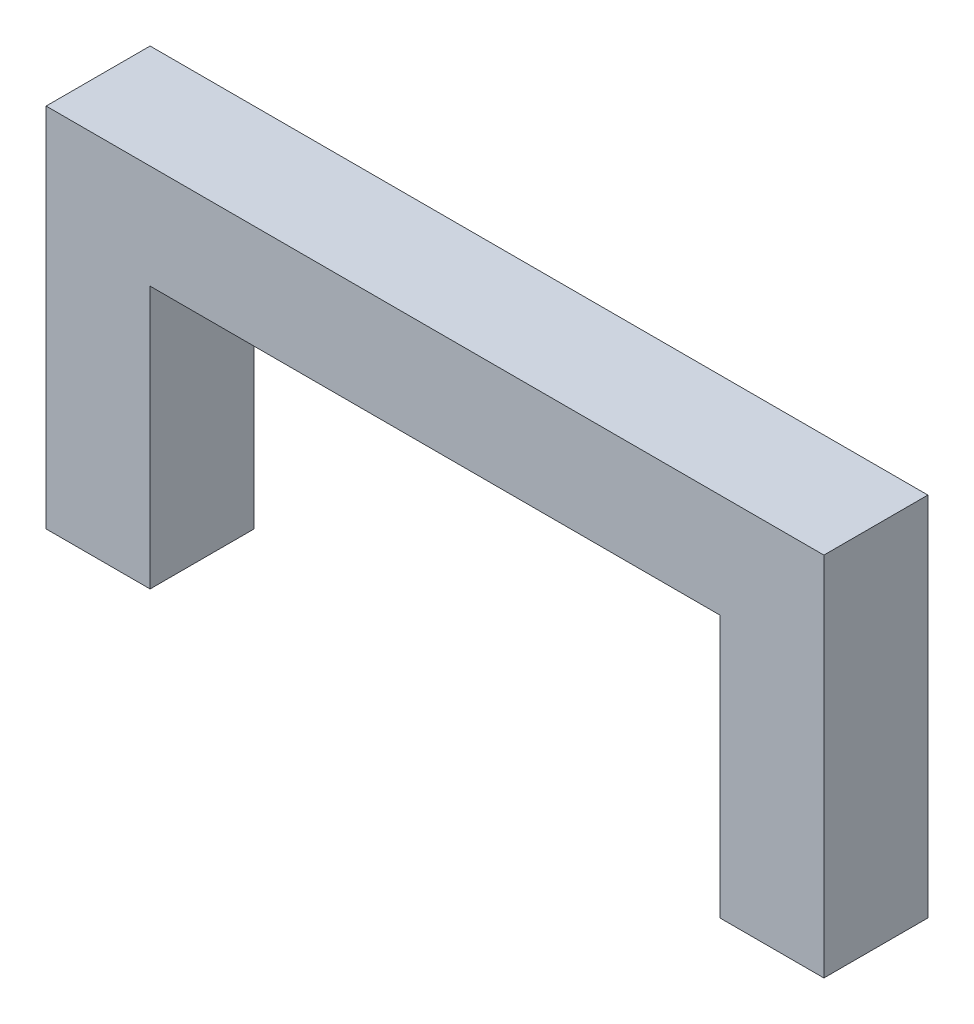
from build123d import *

# Parameters (mm, degrees)
SKETCH2_W             = 19.05
SKETCH2_H             = 19.05
BOSS_EXTRUDE1_DEPTH   = 48.05
BOSS_EXTRUDE1_2_DEPTH = 48.05
SKETCH3_W             = 142.49
SKETCH3_H             = 19.05
BOSS_EXTRUDE2_DEPTH   = 19.05


with BuildPart() as part:
    # Sketch2 → Boss-Extrude1 (new body)
    with BuildSketch(Plane(origin=(0, 0, 0), x_dir=(1, 0, 0), z_dir=(0, 1, 0))):
        with Locations((9.525, -9.525)):
            Rectangle(SKETCH2_W, SKETCH2_H)
    extrude(amount=BOSS_EXTRUDE1_DEPTH)



with BuildPart() as body_2:
    # Sketch2 → Boss-Extrude1 2 (new body)
    with BuildSketch(Plane(origin=(0, 0, 0), x_dir=(1, 0, 0), z_dir=(0, 1, 0))):
        with Locations((132.965, -9.525)):
            Rectangle(SKETCH2_W, SKETCH2_H)
    extrude(amount=BOSS_EXTRUDE1_2_DEPTH)


with BuildPart() as part_1:
    add(part.part)

    add(body_2.part)  # Boss-Extrude2 merges body 2
    # Sketch3 → Boss-Extrude2 (add)
    with BuildSketch(Plane(origin=(0, 48.05, 0), x_dir=(1, 0, 0), z_dir=(0, 1, 0))):
        with Locations((71.245, -9.525)):
            Rectangle(SKETCH3_W, SKETCH3_H)
    extrude(amount=BOSS_EXTRUDE2_DEPTH)


solid = part_1.part
